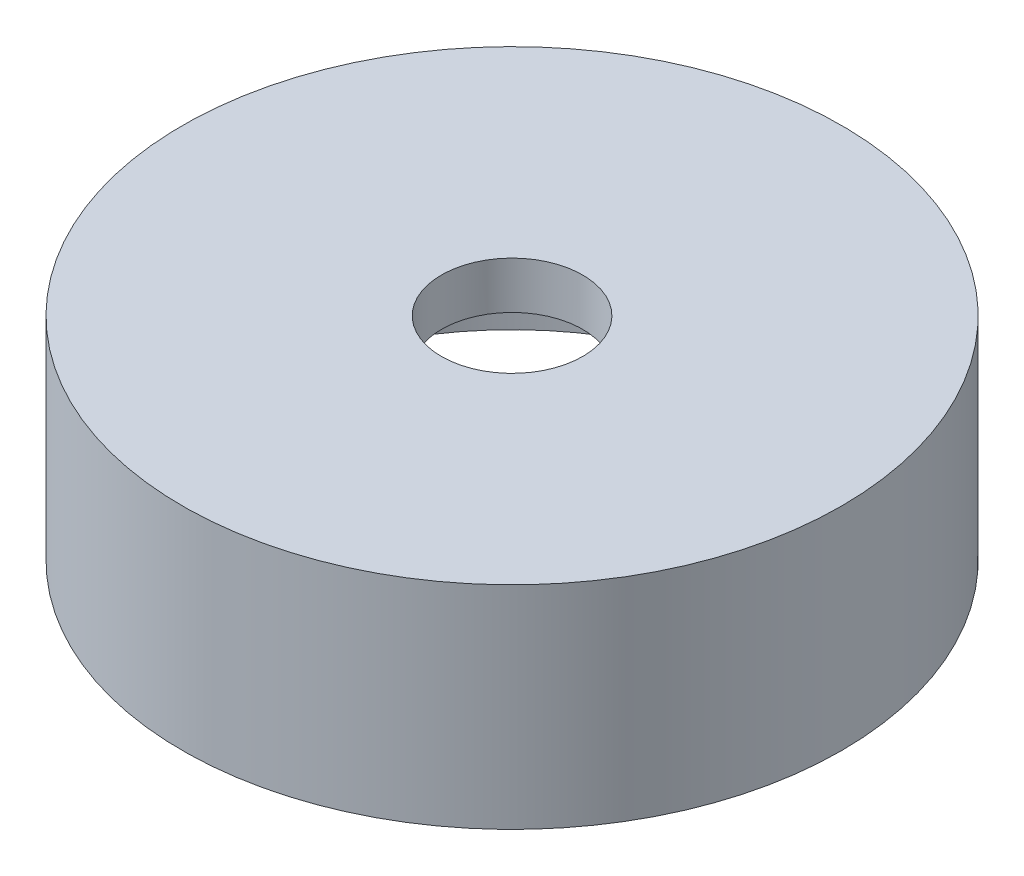
from build123d import *

# Parameters (mm, degrees)
F_3_0MM_DOWEL_HOLE1_D     = 3
F_3_0MM_DOWEL_HOLE1_DEPTH = 7.598709071
F_3_0MM_DOWEL_HOLE1_TIP   = 0.901290929


with BuildPart() as part:
    # Sketch1 → Revolve1 (revolve)
    with BuildSketch(Plane.XY):
        Polygon((0, 4.5), (7, 4.5), (7, 0), (6, 0), (6, 3.5), (0, 3.5), align=None)
    revolve(axis=Axis((0, 0, 0), (0, 1, 0)))

    # Ø3.0mm Dowel Hole1
    with Locations(Plane(origin=(0, 4.5, 0), x_dir=(1, 0, 0), z_dir=(0, 1, 0))):
        with Locations((0, 0)):
            Hole(F_3_0MM_DOWEL_HOLE1_D / 2, depth=F_3_0MM_DOWEL_HOLE1_DEPTH)
            with Locations((0, 0, -(F_3_0MM_DOWEL_HOLE1_DEPTH + F_3_0MM_DOWEL_HOLE1_TIP / 2))):  # 118° drill point
                Cone(0, F_3_0MM_DOWEL_HOLE1_D / 2, F_3_0MM_DOWEL_HOLE1_TIP, mode=Mode.SUBTRACT)


solid = part.part
